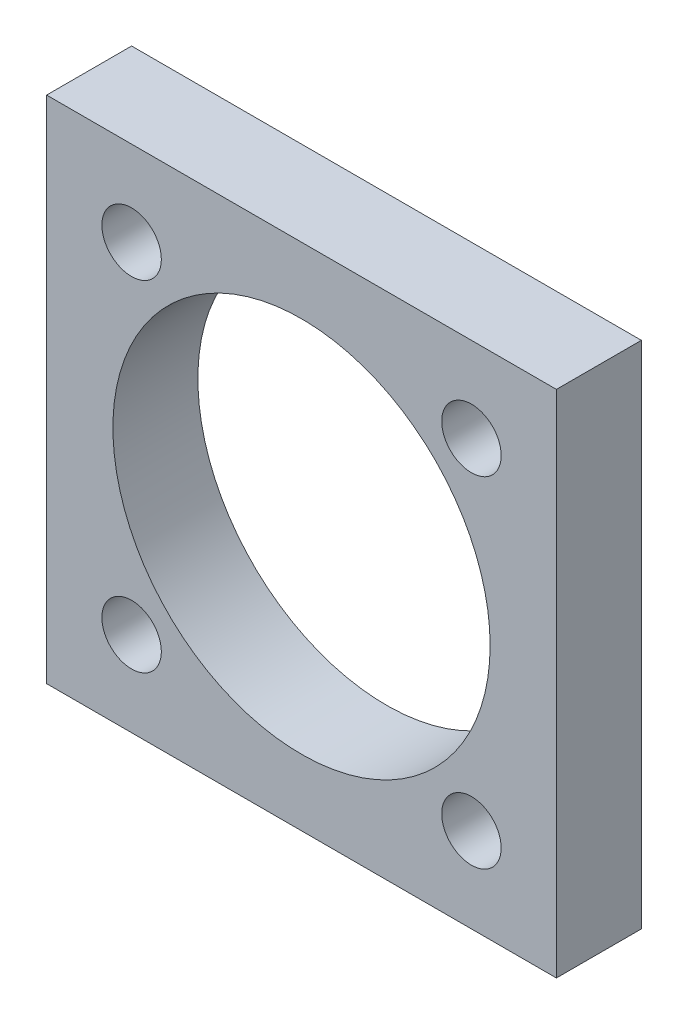
from build123d import *

# Parameters (mm, degrees)
SCHIZZO1_W                   = 30
SCHIZZO1_H                   = 30
SCHIZZO1_R                   = 1.75
SCHIZZO1_R_2                 = 11.1
ESTRUSIONE_ESTRUSIONE1_DEPTH = 5


with BuildPart() as part:
    # Schizzo1 → Estrusione-Estrusione1 (new body)
    with BuildSketch(Plane.XY):
        Rectangle(SCHIZZO1_W, SCHIZZO1_H)
        with Locations((-10, 10)):
            Circle(SCHIZZO1_R, mode=Mode.SUBTRACT)
        with Locations((10, 10)):
            Circle(SCHIZZO1_R, mode=Mode.SUBTRACT)
        with Locations((10, -10)):
            Circle(SCHIZZO1_R, mode=Mode.SUBTRACT)
        with Locations((-10, -10)):
            Circle(SCHIZZO1_R, mode=Mode.SUBTRACT)
        Circle(SCHIZZO1_R_2, mode=Mode.SUBTRACT)
    extrude(amount=ESTRUSIONE_ESTRUSIONE1_DEPTH)


solid = part.part
